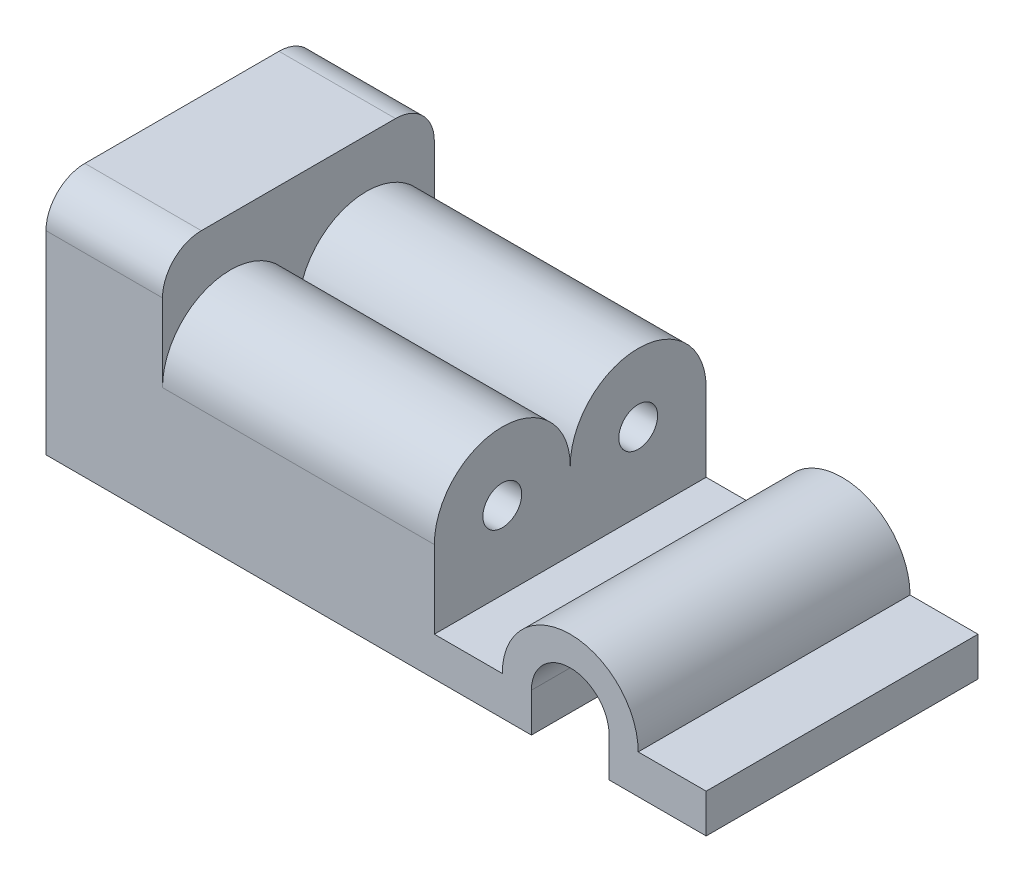
from build123d import *

# Parameters (mm, degrees)
BOSS_EXTRUDE1_DEPTH = 35
FILLET1_R           = 10
FILLET2_R           = 10
BOSS_EXTRUDE2_DEPTH = 70
SKETCH4_R           = 5
CUT_EXTRUDE1_DEPTH  = 70


with BuildPart() as part:
    # Sketch1 → Boss-Extrude1 (new body, symmetric)
    with BuildSketch(Plane.XY):
        with BuildLine():
            Line((-75.172413793, -24.310344828), (-75.172413793, 35.689655172))
            Line((-75.172413793, 35.689655172), (-45.172413793, 35.689655172))
            Line((-45.172413793, 35.689655172), (-45.172413793, 5.689655172))
            Line((-45.172413793, 5.689655172), (24.827586207, 5.689655172))
            Line((24.827586207, 5.689655172), (24.827586207, -14.310344828))
            Line((24.827586207, -14.310344828), (42.32758867, -14.310344828))
            ThreePointArc((42.32758867, -14.310344828), (59.827586207, 3.198940398), (77.327583744, -14.310344828))
            Line((77.327583744, -14.310344828), (94.827586207, -14.310344828))
            Line((94.827586207, -14.310344828), (94.827586207, -24.310344828))
            Line((94.827586207, -24.310344828), (69.827586207, -24.310344828))
            Line((69.827586207, -24.310344828), (69.827586207, -14.301059602))
            ThreePointArc((69.827586207, -14.301059602), (59.827586207, -4.301059602), (49.827586207, -14.301059602))
            Line((49.827586207, -14.301059602), (49.827586207, -24.310344828))
            Line((49.827586207, -24.310344828), (-75.172413793, -24.310344828))
        make_face()
    extrude(amount=BOSS_EXTRUDE1_DEPTH, both=True)

    # Fillet1
    fillet1_edges = [part.edges().sort_by_distance(p)[0] for p in [
        (-60.172413793, 35.689655172, 35),
    ]]
    fillet(fillet1_edges, radius=FILLET1_R)

    # Fillet2
    fillet2_edges = [part.edges().sort_by_distance(p)[0] for p in [
        (-60.172413793, 35.689655172, -35),
    ]]
    fillet(fillet2_edges, radius=FILLET2_R)

    # Sketch3 → Boss-Extrude2 (add)
    with BuildSketch(Plane(origin=(-45.172413793, 0, 0), x_dir=(0, 0, -1), z_dir=(1, 0, 0))):
        with BuildLine():
            ThreePointArc((0, 5.689655172), (-17.5, 23.189655172), (-35, 5.689655172))
            Line((-35, 5.689655172), (0, 5.689655172))
        make_face()
        with BuildLine():
            ThreePointArc((35, 5.689655172), (17.5, 23.189655172), (0, 5.689655172))
            Line((0, 5.689655172), (35, 5.689655172))
        make_face()
    extrude(amount=BOSS_EXTRUDE2_DEPTH)

    # Sketch4 → Cut-Extrude1 (cut)
    with BuildSketch(Plane(origin=(24.827586207, 0, 0), x_dir=(0, 0, -1), z_dir=(1, 0, 0))):
        with Locations((-17.5, 5.689655172)):
            Circle(SKETCH4_R)
        with Locations((17.5, 5.689655172)):
            Circle(SKETCH4_R)
    extrude(amount=-CUT_EXTRUDE1_DEPTH, mode=Mode.SUBTRACT)


solid = part.part
